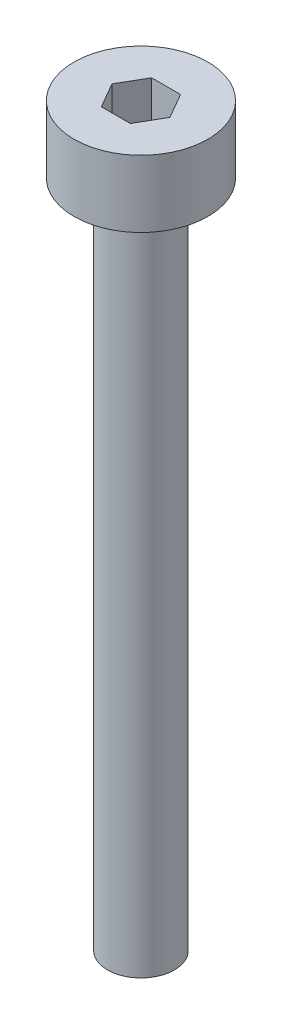
from build123d import *

# Parameters (mm, degrees)
SKETCH_1_R            = 2
EXTRUDE_246_DEPTH     = 2
CUT_EXTRUDE_376_DEPTH = 1.5
SKETCH_3_R            = 1
EXTRUDE_477_DEPTH     = 20


with BuildPart() as part:
    # 草图1 → Extrude 246 (new body)
    with BuildSketch(Plane(origin=(0, 0, 0), x_dir=(1, 0, 0), z_dir=(0, 1, 0))):
        Circle(SKETCH_1_R)
    extrude(amount=EXTRUDE_246_DEPTH)

    # 草图2 → Cut-Extrude 376 (cut)
    with BuildSketch(Plane(origin=(0, 2, 0), x_dir=(1, 0, 0), z_dir=(0, 1, 0))):
        Polygon((0.866025404, 0), (0.433012702, 0.75), (-0.433012702, 0.75), (-0.866025404, 0), (-0.433012702, -0.75), (0.433012702, -0.75), align=None)
    extrude(amount=-CUT_EXTRUDE_376_DEPTH, mode=Mode.SUBTRACT)

    # 草图3 → Extrude 477 (add)
    with BuildSketch(Plane.XZ):
        Circle(SKETCH_3_R)
    extrude(amount=EXTRUDE_477_DEPTH)


solid = part.part
